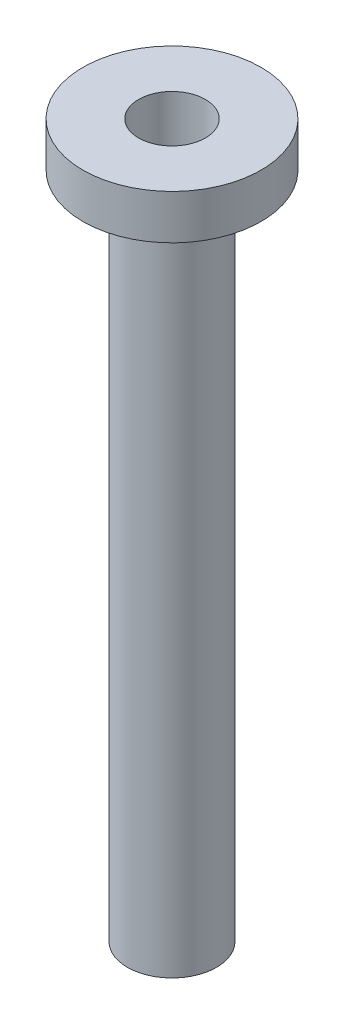
from build123d import *

# Parameters (mm, degrees)
F_3_8_0_375_DIAMETER_HOLE1_D     = 9.525
F_3_8_0_375_DIAMETER_HOLE1_DEPTH = 95.25
F_3_8_0_375_DIAMETER_HOLE1_TIP   = 2.861598698


with BuildPart() as part:
    # Sketch1 → Revolve1 (revolve)
    with BuildSketch(Plane.XY):
        Polygon((0, 0), (0, -101.6), (-6.35, -101.6), (-6.35, -6.35), (-12.7, -6.35), (-12.7, 0), align=None)
    revolve(axis=Axis((0, 0, 0), (0, -1, 0)))

    # 3/8 (0.375) Diameter Hole1
    with Locations(Plane(origin=(0, 0, 0), x_dir=(1, 0, 0), z_dir=(0, 1, 0))):
        with Locations((0, 0)):
            Hole(F_3_8_0_375_DIAMETER_HOLE1_D / 2, depth=F_3_8_0_375_DIAMETER_HOLE1_DEPTH)
            with Locations((0, 0, -(F_3_8_0_375_DIAMETER_HOLE1_DEPTH + F_3_8_0_375_DIAMETER_HOLE1_TIP / 2))):  # 118° drill point
                Cone(0, F_3_8_0_375_DIAMETER_HOLE1_D / 2, F_3_8_0_375_DIAMETER_HOLE1_TIP, mode=Mode.SUBTRACT)


solid = part.part
